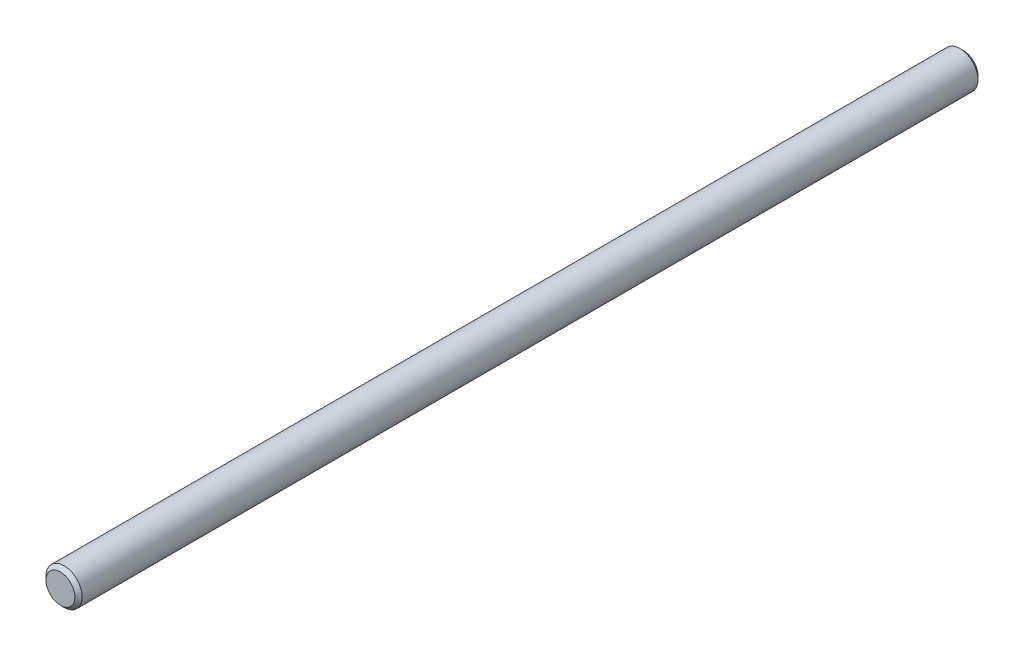
from build123d import *

# Parameters (mm, degrees)
SKETCH1_R      = 5
EXTRUDE1_DEPTH = 125
CHAMFER1_SIZE  = 1


with BuildPart() as part:
    # Sketch1 → Extrude1 (new body, symmetric)
    with BuildSketch(Plane.XY):
        Circle(SKETCH1_R)
    extrude(amount=EXTRUDE1_DEPTH, both=True)

    # Chamfer1
    chamfer1_edges = [part.edges().sort_by_distance(p)[0] for p in [
        (-5, 0, -125),
        (-5, 0, 125),
    ]]
    chamfer(chamfer1_edges, length=CHAMFER1_SIZE)


solid = part.part
